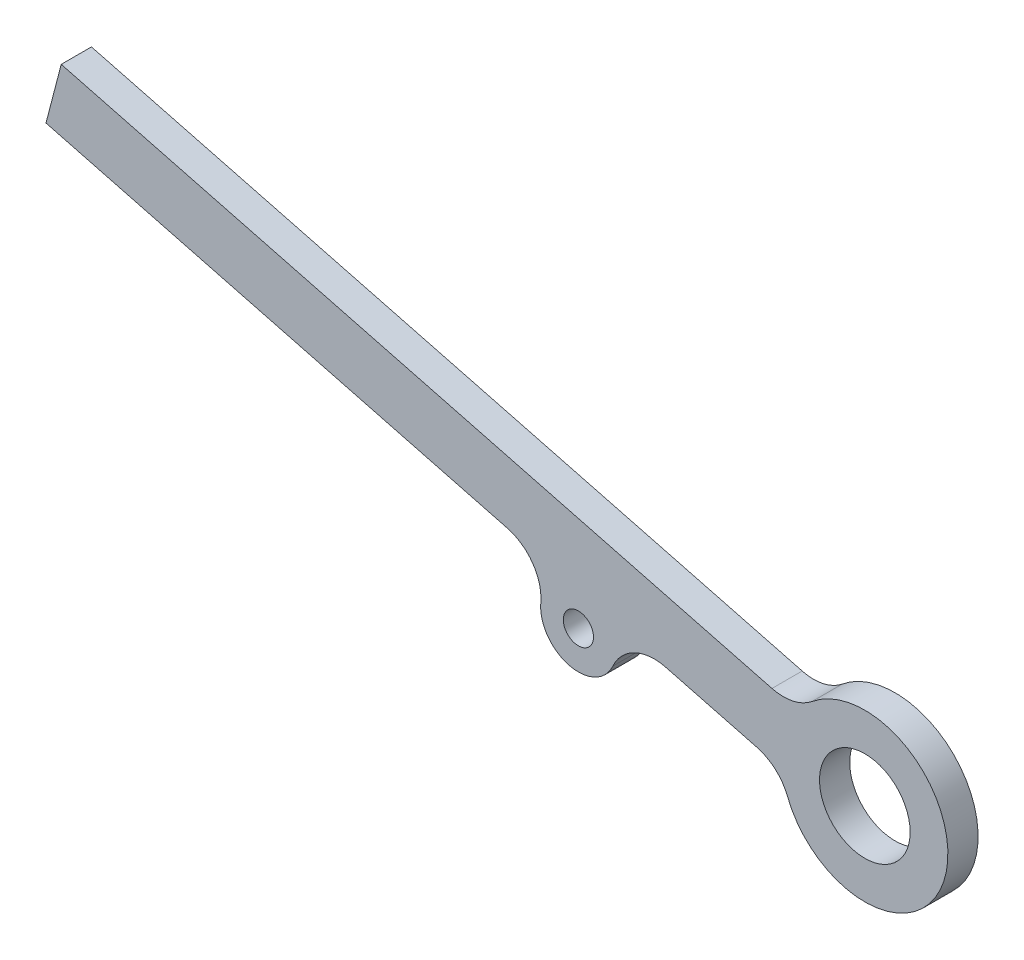
from build123d import *

# Parameters (mm, degrees)
SKETCH1_R           = 1
SKETCH1_R_2         = 3
BOSS_EXTRUDE1_DEPTH = 2


with BuildPart() as part:
    # Sketch1 → Boss-Extrude1 (new body)
    with BuildSketch(Plane.XY):
        with BuildLine():
            Line((11.808151179, -0.905709908), (5.779825316, 0.664336707))
            ThreePointArc((5.779825316, 0.664336707), (3.723166432, 0.464621774), (2.283506385, -1.017643645))
            ThreePointArc((2.283506385, -1.017643645), (-0.630092723, -2.419293938), (-2.489805466, 0.225540995))
            ThreePointArc((-2.489805466, 0.225540995), (-3.023512134, 2.221759674), (-4.721460758, 3.399342916))
            Line((-4.721460758, 3.399342916), (-35.248215692, 11.34987999))
            Line((-35.248215692, 11.34987999), (-34.240067334, 15.220750291))
            Line((-34.240067334, 15.220750291), (12.816299536, 2.965160393))
            ThreePointArc((12.816299536, 2.965160393), (14.215899346, 2.938138637), (15.47538955, 3.54911673))
            ThreePointArc((15.47538955, 3.54911673), (24.286630582, -2.088947309), (13.844561325, -2.712585228))
            ThreePointArc((13.844561325, -2.712585228), (13.043119538, -1.564847947), (11.808151179, -0.905709908))
        make_face()
        Circle(SKETCH1_R, mode=Mode.SUBTRACT)
        with Locations((18.964183918, -0.702743317)):
            Circle(SKETCH1_R_2, mode=Mode.SUBTRACT)
    extrude(amount=BOSS_EXTRUDE1_DEPTH)


solid = part.part
